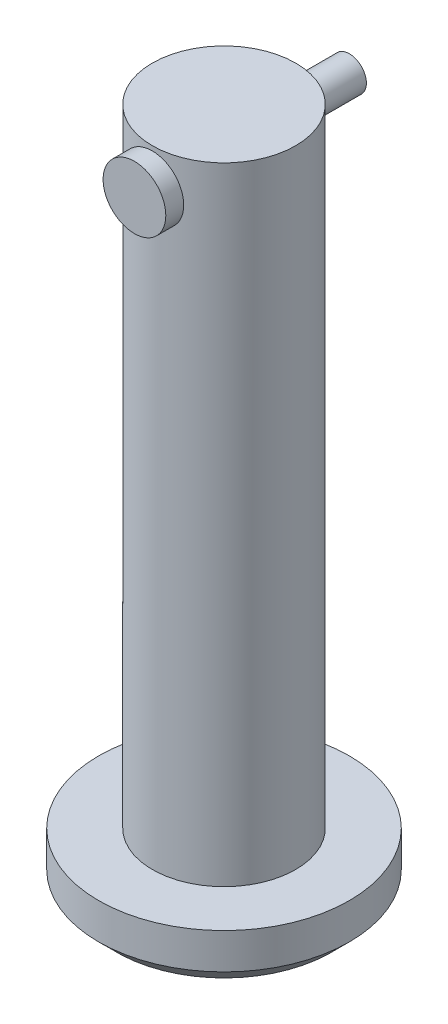
from build123d import *

# Parameters (mm, degrees)
SKETCH1_R                = 4
BOSS_EXTRUDE1_DEPTH      = 35
SKETCH2_R                = 7
BOSS_EXTRUDE2_DEPTH      = 3
CHAMFER1_SIZE            = 1
SKETCH3_R                = 1
CUT_EXTRUDE1_DEPTH       = 10
CUT_EXTRUDE1_DEPTH_BACK  = 10
SKETCH4_R                = 0.95
BOSS_EXTRUDE3_DEPTH      = 5
BOSS_EXTRUDE3_DEPTH_BACK = 7
SKETCH5_R                = 1.75
BOSS_EXTRUDE4_DEPTH      = 1


with BuildPart() as part:
    # Sketch1 → Boss-Extrude1 (new body)
    with BuildSketch(Plane(origin=(0, 0, 0), x_dir=(1, 0, 0), z_dir=(0, 1, 0))):
        Circle(SKETCH1_R)
    extrude(amount=BOSS_EXTRUDE1_DEPTH)

    # Sketch2 → Boss-Extrude2 (add)
    with BuildSketch(Plane.XZ):
        Circle(SKETCH2_R)
    extrude(amount=BOSS_EXTRUDE2_DEPTH)

    # Chamfer1
    chamfer1_edges = [part.edges().sort_by_distance(p)[0] for p in [
        (-7, -3, 0),
    ]]
    chamfer(chamfer1_edges, length=CHAMFER1_SIZE)

    # Sketch3 → Cut-Extrude1 (cut, two sides)
    with BuildSketch(Plane.XY) as cut_extrude1_sk:
        with Locations((0, 33)):
            Circle(SKETCH3_R)
    extrude(amount=CUT_EXTRUDE1_DEPTH, mode=Mode.SUBTRACT)
    extrude(cut_extrude1_sk.sketch, amount=-CUT_EXTRUDE1_DEPTH_BACK, mode=Mode.SUBTRACT)


with BuildPart() as body_2:
    # Sketch4 → Boss-Extrude3 (new body, two sides)
    with BuildSketch(Plane.XY) as boss_extrude3_sk:
        with Locations((0, 33)):
            Circle(SKETCH4_R)
    extrude(amount=BOSS_EXTRUDE3_DEPTH)
    extrude(boss_extrude3_sk.sketch, amount=-BOSS_EXTRUDE3_DEPTH_BACK)

    # Sketch5 → Boss-Extrude4 (add)
    with BuildSketch(Plane.XY.offset(5)):
        with Locations((0, 33)):
            Circle(SKETCH5_R)
    extrude(amount=-BOSS_EXTRUDE4_DEPTH)


solid = Compound([part.part, body_2.part])
